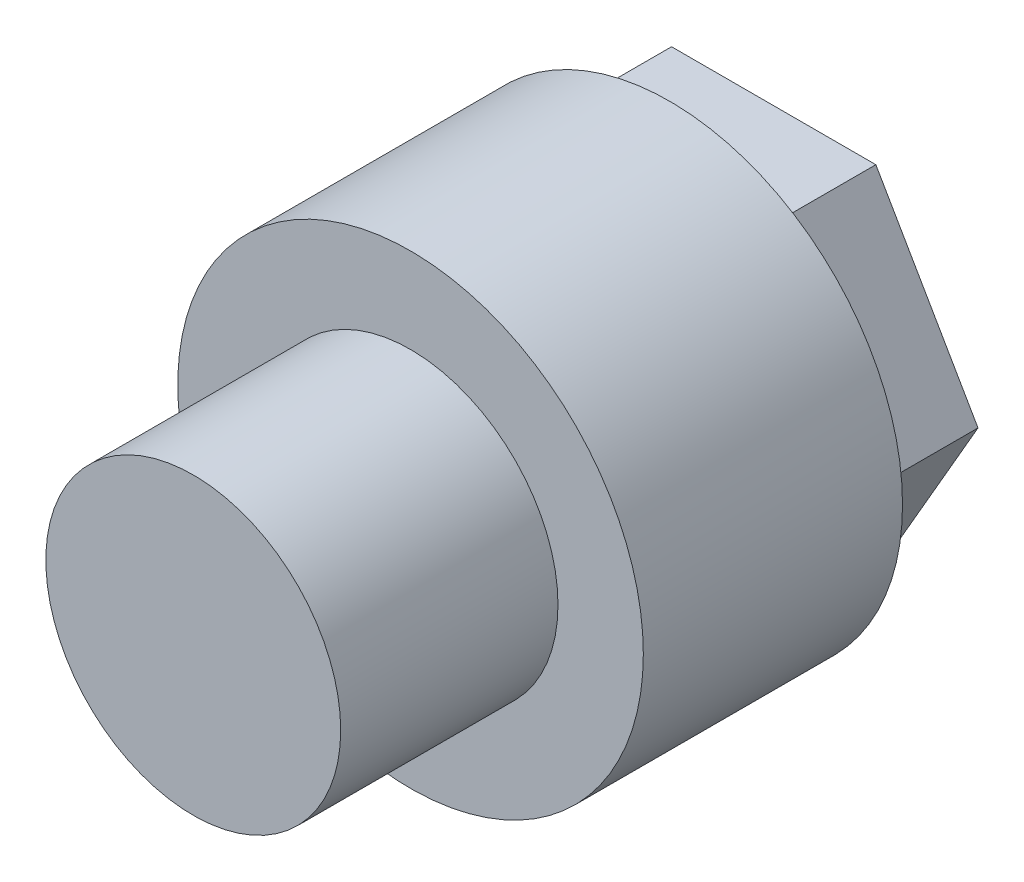
from build123d import *

# Parameters (mm, degrees)
SKETCH1_R           = 7.5
SKETCH1_R_2         = 4.75
BOSS_EXTRUDE1_DEPTH = 8.35
BOSS_EXTRUDE2_DEPTH = 3.35
BOSS_EXTRUDE3_START = 8.35
SKETCH1_4_R         = 4.75
BOSS_EXTRUDE3_DEPTH = 7


with BuildPart() as part:
    # Sketch1 → Boss-Extrude1 (new body)
    with BuildSketch(Plane.XY):
        Circle(SKETCH1_R)
        Polygon((-3.290896534, 5.7), (-6.581793069, 0), (-3.290896534, -5.7), (3.290896534, -5.7), (6.581793069, 0), (3.290896534, 5.7), align=None, mode=Mode.SUBTRACT)
        Circle(SKETCH1_R)
        Circle(SKETCH1_R_2, mode=Mode.SUBTRACT)
        Circle(SKETCH1_R_2)
    extrude(amount=BOSS_EXTRUDE1_DEPTH)

    # Sketch1_3 → Boss-Extrude2 (add)
    with BuildSketch(Plane.XY):
        Polygon((-3.290896534, -5.7), (3.290896534, -5.7), (6.581793069, 0), (3.290896534, 5.7), (-3.290896534, 5.7), (-6.581793069, 0), align=None)
    extrude(amount=-BOSS_EXTRUDE2_DEPTH)

    # Sketch1_4 → Boss-Extrude3 (add)
    with BuildSketch(Plane.XY.offset(BOSS_EXTRUDE3_START)):
        Circle(SKETCH1_4_R)
    extrude(amount=BOSS_EXTRUDE3_DEPTH)


solid = part.part
